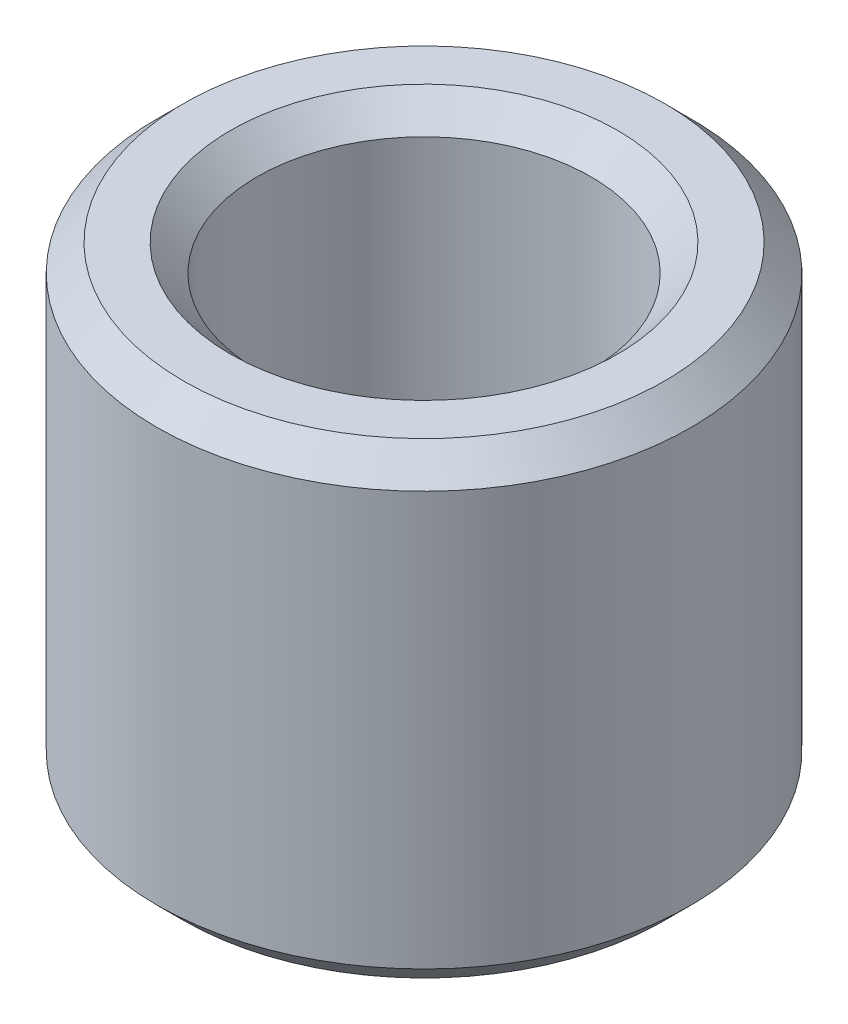
from build123d import *

# Parameters (mm, degrees)
SKETCH1_R           = 2
SKETCH1_R_2         = 1.25
BOSS_EXTRUDE1_DEPTH = 3.497
CHAMFER1_SIZE       = 0.2


with BuildPart() as part:
    # Sketch1 → Boss-Extrude1 (new body)
    with BuildSketch(Plane(origin=(0, 0, 0), x_dir=(1, 0, 0), z_dir=(0, 1, 0))):
        Circle(SKETCH1_R)
        Circle(SKETCH1_R_2, mode=Mode.SUBTRACT)
    extrude(amount=BOSS_EXTRUDE1_DEPTH)

    # Chamfer1
    chamfer1_edges = [part.edges().sort_by_distance(p)[0] for p in [
        (-2, 0, 0),
        (-2, 3.497, 0),
        (-1.25, 0, 0),
        (-1.25, 3.497, 0),
    ]]
    chamfer(chamfer1_edges, length=CHAMFER1_SIZE)


solid = part.part
